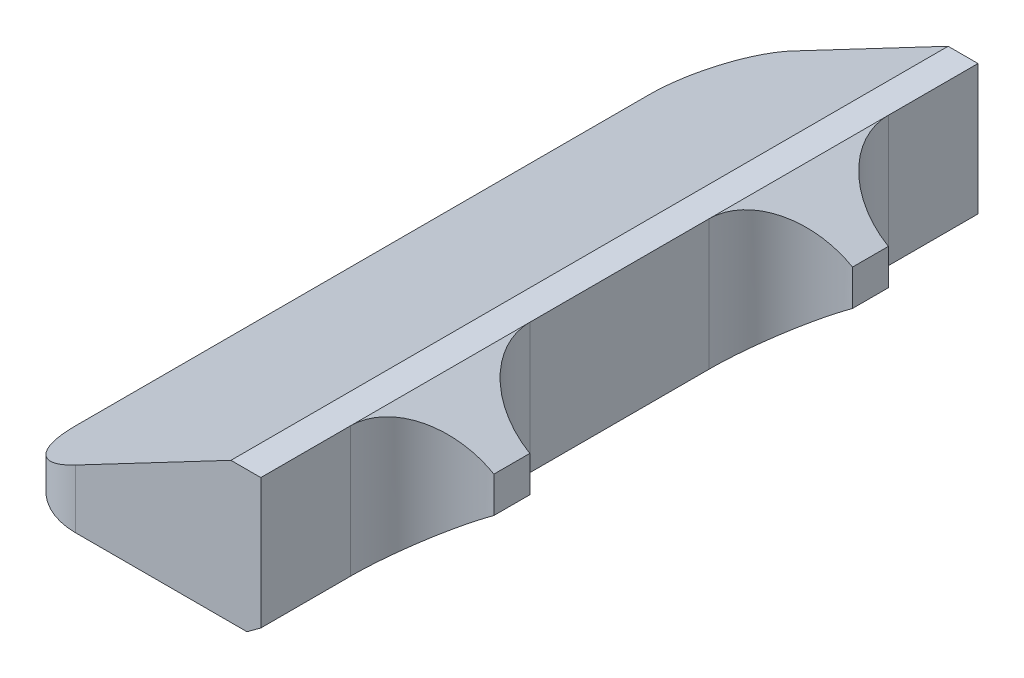
from build123d import *

# Parameters (mm, degrees)
EXTRUDE1_DEPTH     = 60
CUT_EXTRUDE1_DEPTH = 13
FILLET1_R          = 6
CHAMFER1_SIZE      = 0.25


with BuildPart() as part:
    # Sketch1 → Extrude1 (new body)
    with BuildSketch(Plane.XY):
        Polygon((0, 0), (20, 0), (27.5, 5.5), (27.5, 8.5), (21.5, 12), (19, 12), (0, 2), align=None)
    extrude(amount=EXTRUDE1_DEPTH)

    # Sketch2 → Cut-Extrude1 (cut, through all)
    with BuildSketch(Plane(origin=(0, 0, 0), x_dir=(1, 0, 0), z_dir=(0, 1, 0))):
        with BuildLine():
            Line((27.5, -13.5), (27.5, -16.5))
            ThreePointArc((27.5, -16.5), (23.257359313, -18.257359313), (21.5, -22.5))
            Line((21.5, -22.5), (21.5, -37.5))
            ThreePointArc((21.5, -37.5), (23.257359313, -41.742640687), (27.5, -43.5))
            Line((27.5, -43.5), (27.5, -46.5))
            ThreePointArc((27.5, -46.5), (23.257359313, -48.257359313), (21.5, -52.5))
            Line((21.5, -52.5), (21.5, -60))
            Line((21.5, -60), (28.5, -60))
            Line((28.5, -60), (28.5, 0))
            Line((28.5, 0), (21.5, 0))
            Line((21.5, 0), (21.5, -7.5))
            ThreePointArc((21.5, -7.5), (23.257359313, -11.742640687), (27.5, -13.5))
        make_face()
    extrude(amount=CUT_EXTRUDE1_DEPTH, mode=Mode.SUBTRACT)

    # Fillet1
    fillet1_edges = [part.edges().sort_by_distance(p)[0] for p in [
        (0, 1, 60),
        (0, 1, 0),
    ]]
    fillet(fillet1_edges, radius=FILLET1_R)

    # Chamfer1
    chamfer1_edges = [part.edges().sort_by_distance(p)[0] for p in [
        (0, 0, 30),
        (13, 0, 0),
        (13, 0, 60),
        (1.757359313, 0, 58.242640687),
        (1.757359313, 0, 1.757359313),
    ]]
    chamfer(chamfer1_edges, length=CHAMFER1_SIZE)


solid = part.part
